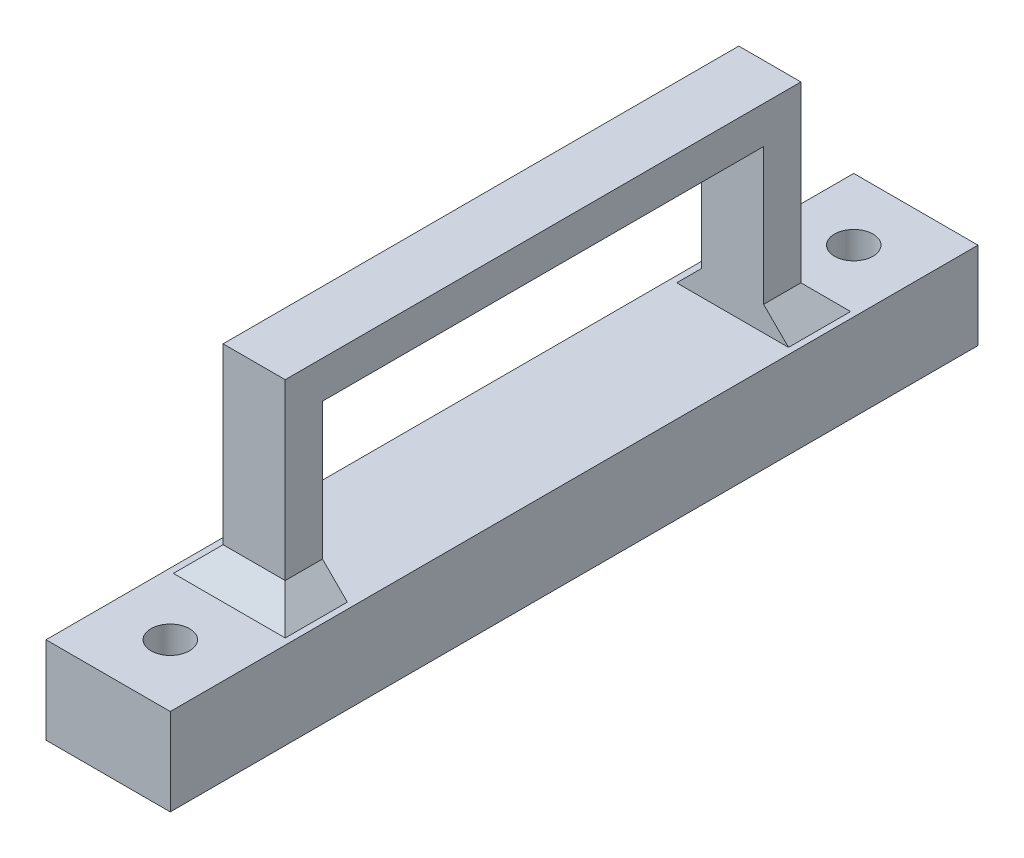
from build123d import *

# Parameters (mm, degrees)
SKETCH1_W           = 10
SKETCH1_H           = 65
SKETCH1_R           = 1.55
BOSS_EXTRUDE1_DEPTH = 7
SKETCH2_W           = 5
SKETCH2_H           = 3
BOSS_EXTRUDE2_DEPTH = 16
SKETCH3_W           = 5
SKETCH3_H           = 3
BOSS_EXTRUDE3_DEPTH = 35.5
CHAMFER1_SIZE       = 2


with BuildPart() as part:
    # Sketch1 → Boss-Extrude1 (new body)
    with BuildSketch(Plane(origin=(0, 0, 0), x_dir=(1, 0, 0), z_dir=(0, 1, 0))):
        with Locations((5, 32.5)):
            Rectangle(SKETCH1_W, SKETCH1_H)
        with Locations((5, 60)):
            Circle(SKETCH1_R, mode=Mode.SUBTRACT)
        with Locations((5, 5)):
            Circle(SKETCH1_R, mode=Mode.SUBTRACT)
    extrude(amount=BOSS_EXTRUDE1_DEPTH)

    # Sketch2 → Boss-Extrude2 (add)
    with BuildSketch(Plane(origin=(0, 7, 0), x_dir=(1, 0, 0), z_dir=(0, 1, 0))):
        with Locations((5, 51.75)):
            Rectangle(SKETCH2_W, SKETCH2_H)
        with Locations((5, 13.25)):
            Rectangle(SKETCH2_W, SKETCH2_H)
    extrude(amount=BOSS_EXTRUDE2_DEPTH)

    # Sketch3 → Boss-Extrude3 (add)
    with BuildSketch(Plane.XY.offset(-50.25)):
        with Locations((5, 21.5)):
            Rectangle(SKETCH3_W, SKETCH3_H)
    extrude(amount=BOSS_EXTRUDE3_DEPTH)

    # Chamfer1
    chamfer1_edges = [part.edges().sort_by_distance(p)[0] for p in [
        (7.5, 7, -51.75),
        (5, 7, -53.25),
        (2.5, 7, -51.75),
        (7.5, 7, -13.25),
        (2.5, 7, -13.25),
        (5, 7, -11.75),
    ]]
    chamfer(chamfer1_edges, length=CHAMFER1_SIZE)


solid = part.part
